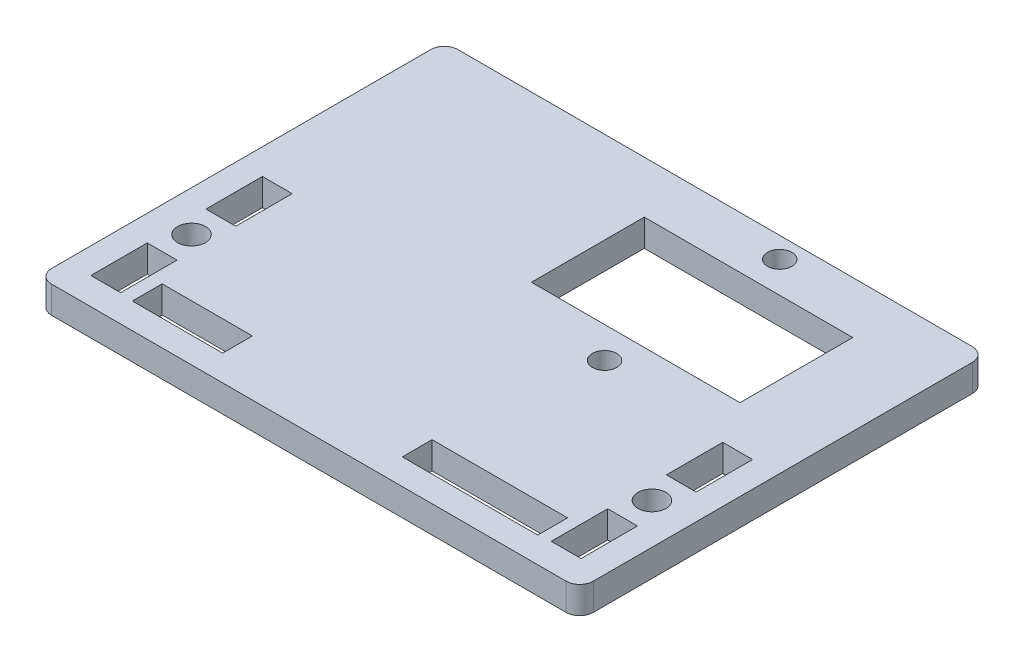
from build123d import *

# Parameters (mm, degrees)
BOSS_EXTRUDE1_DEPTH     = 3
SKETCH2_R               = 1.35
SKETCH2_R_2             = 1.55
SKETCH2_W               = 23.1
SKETCH2_H               = 12.5
SKETCH2_W_2             = 15
SKETCH2_H_2             = 3
SKETCH2_W_3             = 10
SKETCH2_W_4             = 3
SKETCH2_H_3             = 6.25
MAIN_HOLE_EXTRUDE_DEPTH = 4
SKETCH3_W               = 10
SKETCH3_H               = 0.15
SKETCH3_W_2             = 15
SKETCH3_W_3             = 0.15
SKETCH3_H_2             = 6.25
CLEARANCE_EXTRUDE_DEPTH = 4


with BuildPart() as part:
    # Sketch1 → Boss-Extrude1 (new body)
    with BuildSketch(Plane(origin=(0, 0, 0), x_dir=(1, 0, 0), z_dir=(0, 1, 0))):
        with BuildLine():
            Line((1.5, 0), (58.5, 0))
            ThreePointArc((58.5, 0), (59.560660172, 0.439339828), (60, 1.5))
            Line((60, 1.5), (60, 43.5))
            ThreePointArc((60, 43.5), (59.560660172, 44.560660172), (58.5, 45))
            Line((58.5, 45), (1.5, 45))
            ThreePointArc((1.5, 45), (0.439339828, 44.560660172), (0, 43.5))
            Line((0, 43.5), (0, 1.5))
            ThreePointArc((0, 1.5), (0.439339828, 0.439339828), (1.5, 0))
        make_face()
    extrude(amount=BOSS_EXTRUDE1_DEPTH)

    # Sketch2 → Main Hole Extrude (cut, through all)
    with BuildSketch(Plane(origin=(0, 3, 0), x_dir=(1, 0, 0), z_dir=(0, 1, 0))):
        with Locations((39.45, 23.3)):
            Circle(SKETCH2_R)
        with Locations((39.45, 42.7)):
            Circle(SKETCH2_R)
        with Locations((4.5, 12.5)):
            Circle(SKETCH2_R_2)
        with Locations((55.5, 12.5)):
            Circle(SKETCH2_R_2)
        with Locations((39.45, 33)):
            Rectangle(SKETCH2_W, SKETCH2_H)
        with Locations((45, 4.5)):
            Rectangle(SKETCH2_W_2, SKETCH2_H_2)
        with Locations((12.6, 4.5)):
            Rectangle(SKETCH2_W_3, SKETCH2_H_2)
        with Locations((4.5, 18.875)):
            Rectangle(SKETCH2_W_4, SKETCH2_H_3)
        with Locations((4.5, 6.125)):
            Rectangle(SKETCH2_W_4, SKETCH2_H_3)
        with Locations((55.5, 18.875)):
            Rectangle(SKETCH2_W_4, SKETCH2_H_3)
        with Locations((55.5, 6.125)):
            Rectangle(SKETCH2_W_4, SKETCH2_H_3)
    extrude(amount=-MAIN_HOLE_EXTRUDE_DEPTH, mode=Mode.SUBTRACT)

    # Sketch3 → Clearance Extrude (cut, through all)
    with BuildSketch(Plane(origin=(0, 3, 0), x_dir=(1, 0, 0), z_dir=(0, 1, 0))):
        with Locations((12.6, 6.075)):
            Rectangle(SKETCH3_W, SKETCH3_H)
        with Locations((12.6, 2.925)):
            Rectangle(SKETCH3_W, SKETCH3_H)
        with Locations((45, 6.075)):
            Rectangle(SKETCH3_W_2, SKETCH3_H)
        with Locations((45, 2.925)):
            Rectangle(SKETCH3_W_2, SKETCH3_H)
        with Locations((6.075, 18.875)):
            Rectangle(SKETCH3_W_3, SKETCH3_H_2)
        with Locations((2.925, 18.875)):
            Rectangle(SKETCH3_W_3, SKETCH3_H_2)
        with Locations((6.075, 6.125)):
            Rectangle(SKETCH3_W_3, SKETCH3_H_2)
        with Locations((2.925, 6.125)):
            Rectangle(SKETCH3_W_3, SKETCH3_H_2)
        with Locations((53.925, 18.875)):
            Rectangle(SKETCH3_W_3, SKETCH3_H_2)
        with Locations((57.075, 18.875)):
            Rectangle(SKETCH3_W_3, SKETCH3_H_2)
        with Locations((57.075, 6.125)):
            Rectangle(SKETCH3_W_3, SKETCH3_H_2)
        with Locations((53.925, 6.125)):
            Rectangle(SKETCH3_W_3, SKETCH3_H_2)
    extrude(amount=-CLEARANCE_EXTRUDE_DEPTH, mode=Mode.SUBTRACT)


solid = part.part
